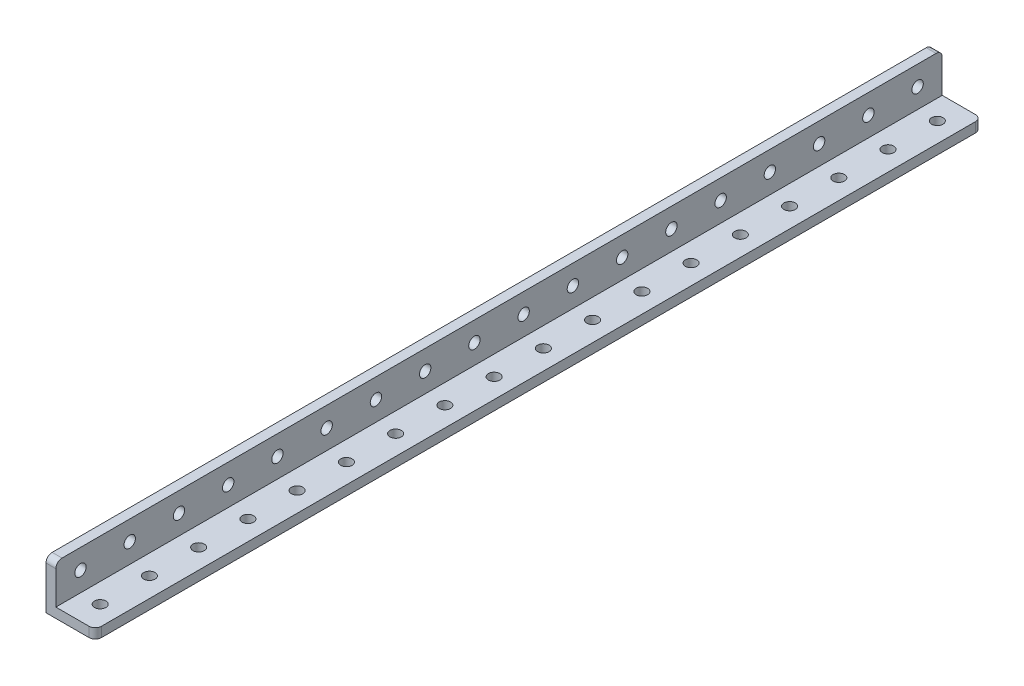
from build123d import *

# Parameters (mm, degrees)
SKETCH1_W                      = 16
SKETCH1_H                      = 288
BOSS_EXTRUDE1_DEPTH            = 16
SKETCH2_W                      = 12.8
SKETCH2_H                      = 12.8
CUT_EXTRUDE1_DEPTH             = 289
F_3_7_3_7_DIAMETER_HOLE1_D     = 3.7
F_3_7_3_7_DIAMETER_HOLE1_DEPTH = 16
F_3_7_3_7_DIAMETER_HOLE2_D     = 3.7
F_3_7_3_7_DIAMETER_HOLE2_DEPTH = 16
FILLET1_R                      = 2


with BuildPart() as part:
    # Sketch1 → Boss-Extrude1 (new body)
    with BuildSketch(Plane(origin=(0, 16, 0), x_dir=(1, 0, 0), z_dir=(0, 1, 0))):
        with Locations((8, 144)):
            Rectangle(SKETCH1_W, SKETCH1_H)
    extrude(amount=-BOSS_EXTRUDE1_DEPTH)

    # Sketch2 → Cut-Extrude1 (cut, through all)
    with BuildSketch(Plane(origin=(0, 0, -288), x_dir=(-1, 0, 0), z_dir=(0, 0, -1))):
        with Locations((-9.6, 9.6)):
            Rectangle(SKETCH2_W, SKETCH2_H)
    extrude(amount=-CUT_EXTRUDE1_DEPTH, mode=Mode.SUBTRACT)

    # Ø3.7 (3.7) Diameter Hole1
    with Locations(Plane(origin=(0, 0, 0), x_dir=(-1, 0, 0), z_dir=(0, -1, 0))):
        with Locations((-9.6, 24), (-9.6, 40), (-9.6, 56), (-9.6, 72), (-9.6, 88), (-9.6, 104), (-9.6, 120), (-9.6, 136), (-9.6, 152), (-9.6, 168), (-9.6, 184), (-9.6, 200), (-9.6, 216), (-9.6, 232), (-9.6, 248), (-9.6, 264), (-9.6, 280), (-9.6, 8)):
            Hole(F_3_7_3_7_DIAMETER_HOLE1_D / 2, depth=F_3_7_3_7_DIAMETER_HOLE1_DEPTH)

    # Ø3.7 (3.7) Diameter Hole2
    with Locations(Plane.ZY):
        with Locations((-24, 9.6), (-40, 9.6), (-56, 9.6), (-72, 9.6), (-88, 9.6), (-104, 9.6), (-120, 9.6), (-136, 9.6), (-152, 9.6), (-168, 9.6), (-184, 9.6), (-200, 9.6), (-216, 9.6), (-232, 9.6), (-248, 9.6), (-264, 9.6), (-280, 9.6), (-8, 9.6)):
            Hole(F_3_7_3_7_DIAMETER_HOLE2_D / 2, depth=F_3_7_3_7_DIAMETER_HOLE2_DEPTH)

    # Fillet1
    fillet1_edges = [part.edges().sort_by_distance(p)[0] for p in [
        (1.6, 16, -288),
        (1.6, 16, 0),
        (16, 1.6, -288),
        (16, 1.6, 0),
    ]]
    fillet(fillet1_edges, radius=FILLET1_R)


solid = part.part
